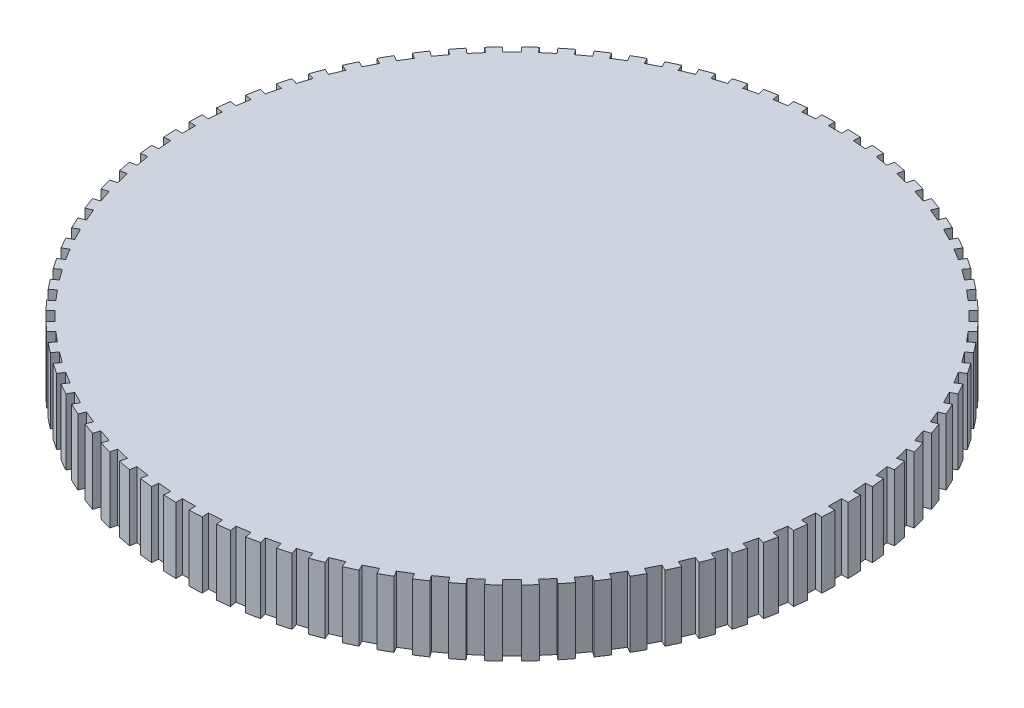
from build123d import *

# Parameters (mm, degrees)
SKETCH_1_R               = 12.5
EXTRUDE_1_DEPTH          = 2.5
SKETCH_2_W               = 0.5
SKETCH_2_H               = 0.5
CUT_EXTRUDE_1_DEPTH      = 5.5
PATTERN_CIRCULAR_1_COUNT = 80


with BuildPart() as part:
    # 草图1 → 凸台-拉伸1 (new body)
    with BuildSketch(Plane(origin=(0, 0, 0), x_dir=(1, 0, 0), z_dir=(0, 1, 0))):
        Circle(SKETCH_1_R)
    extrude(amount=EXTRUDE_1_DEPTH)

    # 草图2 → 切除-拉伸1 (cut)
    with BuildSketch(Plane(origin=(0, 2.5, 0), x_dir=(1, 0, 0), z_dir=(0, 1, 0))):
        with Locations((12.5, 0)):
            Rectangle(SKETCH_2_W, SKETCH_2_H)
    cut_extrude_1 = extrude(amount=-CUT_EXTRUDE_1_DEPTH, mode=Mode.SUBTRACT)

    # 阵列(圆周)1: 切除-拉伸1 ×80 about axis
    pattern_circular_1_axis = Axis((0, 0, 0), (0, 1, 0))
    for i in range(1, PATTERN_CIRCULAR_1_COUNT):
        add(cut_extrude_1.rotate(pattern_circular_1_axis, i * 360 / PATTERN_CIRCULAR_1_COUNT), mode=Mode.SUBTRACT)


solid = part.part
